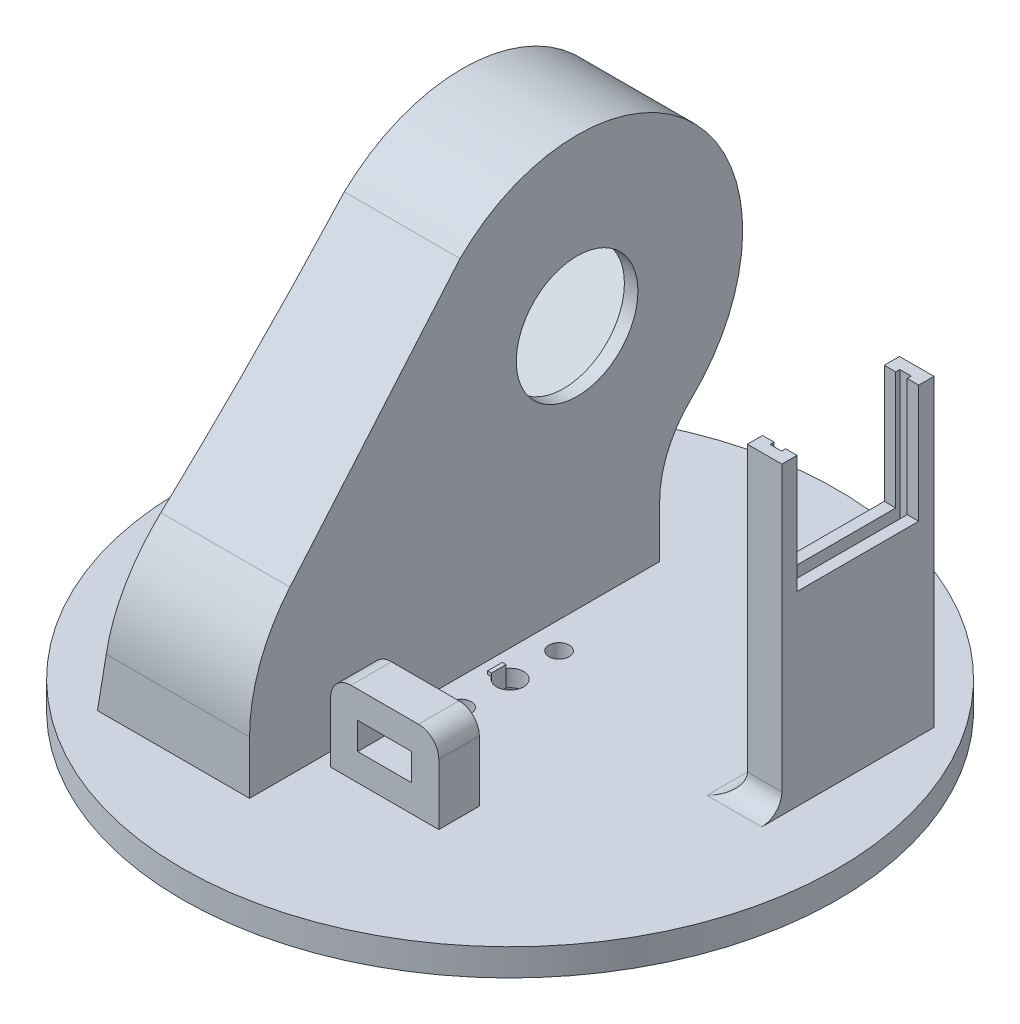
from build123d import *

# Parameters (mm, degrees)
SKETCH2_R                = 48.5
BOSS_EXTRUDE1_DEPTH      = 4
SKETCH4_R                = 1.5
CUT_EXTRUDE2_DEPTH       = 5
SKETCH5_R                = 3.75
CUT_EXTRUDE3_DEPTH       = 1.5
BOSS_EXTRUDE2_DEPTH      = 14
CUT_EXTRUDE5_REACH       = 44.5
SKETCH9_R                = 1.3
CUT_EXTRUDE6_DEPTH       = 7.5
CUT_EXTRUDE9_REACH       = 46.5
SKETCH11_R               = 9
BOSS_EXTRUDE7_DEPTH      = 9
BOSS_EXTRUDE7_DEPTH_BACK = 14
BOSS_EXTRUDE10_DEPTH     = 9
SKETCH27_W               = 16
SKETCH27_H               = 6
BOSS_EXTRUDE11_DEPTH     = 12
FILLET6_R                = 3
CUT_EXTRUDE16_REACH      = 75.05
SKETCH28_W               = 8
SKETCH28_H               = 4
CUT_EXTRUDE17_DEPTH      = 49.5
CUT_EXTRUDE17_DEPTH_BACK = 49.5
CROQUIS4_W               = 5.1
CROQUIS4_H               = 22.5
SALIENTE_EXTRUIR1_DEPTH  = 45
CROQUIS5_W               = 1.7
CROQUIS5_H               = 19.2
CORTAR_EXTRUIR1_DEPTH    = 19.5
CROQUIS6_W               = 18
CROQUIS6_H               = 17.447039648
CORTAR_EXTRUIR2_DEPTH    = 19.5
REDONDEO1_R              = 3
CROQUIS7_R               = 1.99
CORTAR_EXTRUIR3_DEPTH    = 10
CROQUIS8_W               = 0.564126112
CROQUIS8_H               = 2.164439882
SALIENTE_EXTRUIR2_DEPTH  = 3


with BuildPart() as part:
    # Sketch2 → Boss-Extrude1 (new body)
    with BuildSketch(Plane(origin=(0, 0, 0), x_dir=(1, 0, 0), z_dir=(0, 1, 0))):
        Circle(SKETCH2_R)
    extrude(amount=BOSS_EXTRUDE1_DEPTH)

    # Sketch4 → Cut-Extrude2 (cut, through all)
    with BuildSketch(Plane.XZ):
        with Locations((0, 7.25)):
            Circle(SKETCH4_R)
        with Locations((0, -7.25)):
            Circle(SKETCH4_R)
    extrude(amount=-CUT_EXTRUDE2_DEPTH, mode=Mode.SUBTRACT)

    # Sketch5 → Cut-Extrude3 (cut)
    with BuildSketch(Plane.XZ):
        Circle(SKETCH5_R)
    extrude(amount=-CUT_EXTRUDE3_DEPTH, mode=Mode.SUBTRACT)

    # Sketch7 → Boss-Extrude2 (add)
    with BuildSketch(Plane(origin=(-4, 0, 0), x_dir=(0, 0, -1), z_dir=(1, 0, 0))):
        with BuildLine():
            Line((23.129947874, 4), (23.129947874, 11.644549616))
            ThreePointArc((23.129947874, 11.644549616), (24.589048403, 18.743749901), (28.729797284, 24.692011643))
            ThreePointArc((28.729797284, 24.692011643), (29.313383054, 55.284736897), (-1.284289494, 55.479275971))
            Line((-1.284289494, 55.479275971), (-27.227315747, 29.536249718))
            ThreePointArc((-27.227315747, 29.536249718), (-32.64663453, 21.425665997), (-34.549646217, 11.858580188))
            Line((-34.549646217, 11.858580188), (-34.549646217, 4))
            Line((-34.549646217, 4), (23.129947874, 4))
        make_face()
    extrude(amount=-BOSS_EXTRUDE2_DEPTH)

    # Sketch8 → Cut-Extrude5 (cut, up to next)
    with BuildSketch(Plane(origin=(-6, 0, 0), x_dir=(0, 0, -1), z_dir=(1, 0, 0)), mode=Mode.PRIVATE) as cut_extrude5_sk1:
        Polygon((-15.249648422, 25.957567857), (13.741729607, 54.948945886), (28.590972012, 40.099703481), (-0.400406017, 11.108325452), align=None)
    cut_extrude5_tool1 = extrude(cut_extrude5_sk1.sketch, amount=-CUT_EXTRUDE5_REACH, mode=Mode.PRIVATE) & part.part
    add(cut_extrude5_tool1.solids().sort_by_distance((-6, 33.028636, -6.670662))[0], mode=Mode.SUBTRACT)

    # Sketch9 → Cut-Extrude6 (cut)
    with BuildSketch(Plane.ZY.offset(18)):
        with Locations((-20.105690637, 53.534732323)):
            Circle(SKETCH9_R)
        with Locations((-27.176758449, 46.463664511)):
            Circle(SKETCH9_R)
        with Locations((6.764367048, 12.522539014)):
            Circle(SKETCH9_R)
        with Locations((13.83543486, 19.593606826)):
            Circle(SKETCH9_R)
    extrude(amount=-CUT_EXTRUDE6_DEPTH, mode=Mode.SUBTRACT)

    # Sketch11 → Cut-Extrude9 (cut, up to next)
    with BuildSketch(Plane(origin=(-4, 0, 0), x_dir=(0, 0, -1), z_dir=(1, 0, 0)), mode=Mode.PRIVATE) as cut_extrude9_sk1:
        with Locations((13.918506302, 40.276480176)):
            Circle(SKETCH11_R)
    cut_extrude9_tool1 = extrude(cut_extrude9_sk1.sketch, amount=-CUT_EXTRUDE9_REACH, mode=Mode.PRIVATE) & part.part
    add(cut_extrude9_tool1.solids().sort_by_distance((-4, 40.27648, -13.918506))[0], mode=Mode.SUBTRACT)

    # Sketch17 → Boss-Extrude7 (add, two sides)
    with BuildSketch(Plane.ZY.offset(18)) as boss_extrude7_sk:
        with BuildLine():
            ThreePointArc((34.549646217, 11.858580188), (33.008342843, 20.500891953), (28.574482006, 28.077569775))
            ThreePointArc((28.574482006, 28.077569775), (27.915386359, 28.820289685), (27.227315747, 29.536249718))
            Line((27.227315747, 29.536249718), (1.284289494, 55.479275971))
            Line((1.284289494, 55.479275971), (26.295003593, 26.127182305))
            ThreePointArc((26.295003593, 26.127182305), (30.194232218, 19.461281607), (31.549646217, 11.858580188))
            Line((31.549646217, 11.858580188), (31.549646217, 4))
            Line((31.549646217, 4), (34.549646217, 4))
            Line((34.549646217, 4), (34.549646217, 11.858580188))
        make_face()
        with BuildLine():
            Line((28.574482006, 28.077569775), (3.405609837, 57.600596315))
            ThreePointArc((3.405609837, 57.600596315), (-31.461505391, 57.378912253), (-30.796489049, 22.517434639))
            ThreePointArc((-30.796489049, 22.517434639), (-27.345864981, 17.560549854), (-26.129947874, 11.644549616))
            Line((-26.129947874, 11.644549616), (-26.129947874, 4))
            Line((-26.129947874, 4), (-23.129947874, 4))
            Line((-23.129947874, 4), (-23.129947874, 11.644549616))
            ThreePointArc((-23.129947874, 11.644549616), (-24.589048403, 18.743749901), (-28.729797284, 24.692011643))
            ThreePointArc((-28.729797284, 24.692011643), (-29.313383054, 55.284736897), (1.284289494, 55.479275971))
            Line((1.284289494, 55.479275971), (27.227315747, 29.536249718))
            ThreePointArc((27.227315747, 29.536249718), (27.915386359, 28.820289685), (28.574482006, 28.077569775))
        make_face()
    extrude(amount=BOSS_EXTRUDE7_DEPTH)
    extrude(boss_extrude7_sk.sketch, amount=-BOSS_EXTRUDE7_DEPTH_BACK)

    # Sketch25 → Boss-Extrude10 (add)
    with BuildSketch(Plane.ZY.offset(18)):
        with BuildLine():
            ThreePointArc((-28.729797284, 24.692011643), (-24.589048403, 18.743749901), (-23.129947874, 11.644549616))
            Line((-23.129947874, 11.644549616), (-23.129947874, 4))
            Line((-23.129947874, 4), (-15.129947874, 4))
            add(Edge.make_bspline(
                [(-28.729797284, 24.692011643), (-21.954867515, 18.253200081), (-19.09405247, 12.798017691), (-15.129947874, 4)],
                knots=[0, 0, 0, 0, 1, 1, 1, 1], degree=3))
        make_face()
        with BuildLine():
            add(Edge.make_bspline(
                [(11.751619577, 43.19501844), (26.551255916, 25.8264495), (25.549646217, 4)],
                knots=[0, 0, 0, 1, 1, 1], degree=2))
            Line((25.549646217, 4), (31.549646217, 4))
            Line((31.549646217, 4), (31.549646217, 11.858580188))
            ThreePointArc((31.549646217, 11.858580188), (30.194232218, 19.461281607), (26.295003593, 26.127182305))
            Line((26.295003593, 26.127182305), (11.751619577, 43.19501844))
        make_face()
    extrude(amount=BOSS_EXTRUDE10_DEPTH)

    # Sketch27 → Boss-Extrude11 (add)
    with BuildSketch(Plane(origin=(0, 4, 0), x_dir=(1, 0, 0), z_dir=(0, 1, 0))):
        with Locations((6, -21.549646217)):
            Rectangle(SKETCH27_W, SKETCH27_H)
    extrude(amount=BOSS_EXTRUDE11_DEPTH)

    # Fillet6
    fillet6_edges = [part.edges().sort_by_distance(p)[0] for p in [
        (-2, 16, 21.549646217),
        (14, 16, 21.549646217),
    ]]
    fillet(fillet6_edges, radius=FILLET6_R)

    # Sketch28 → Cut-Extrude16 (cut, up to next)
    with BuildSketch(Plane.XY.offset(24.549646217), mode=Mode.PRIVATE) as cut_extrude16_sk1:
        with Locations((6, 10)):
            Rectangle(SKETCH28_W, SKETCH28_H)
    cut_extrude16_tool1 = extrude(cut_extrude16_sk1.sketch, amount=-CUT_EXTRUDE16_REACH, mode=Mode.PRIVATE) & part.part
    add(cut_extrude16_tool1.solids().sort_by_distance((6, 10, 24.549646))[0], mode=Mode.SUBTRACT)

    # Sketch29 → Cut-Extrude17 (cut, two sides)
    with BuildSketch(Plane.XY) as cut_extrude17_sk:
        with BuildLine():
            Line((-21, 64.776480176), (-27, 64.776480176))
            Line((-27, 64.776480176), (-27, 4))
            Line((-27, 4), (-26.5, 4))
            add(Edge.make_bspline(
                [(-21, 64.776480176), (-21.220459696, 34.140901434), (-26.5, 4)],
                knots=[0, 0, 0, 1, 1, 1], degree=2))
        make_face()
    extrude(amount=CUT_EXTRUDE17_DEPTH, mode=Mode.SUBTRACT)
    extrude(cut_extrude17_sk.sketch, amount=-CUT_EXTRUDE17_DEPTH_BACK, mode=Mode.SUBTRACT)

    # Croquis4 → Saliente-Extruir1 (add)
    with BuildSketch(Plane(origin=(0, 4, 0), x_dir=(1, 0, 0), z_dir=(0, 1, 0))):
        with Locations((35, 13.919947874)):
            Rectangle(CROQUIS4_W, CROQUIS4_H)
    extrude(amount=SALIENTE_EXTRUIR1_DEPTH)

    # Croquis5 → Cortar-Extruir1 (cut)
    with BuildSketch(Plane(origin=(0, 49, 0), x_dir=(1, 0, 0), z_dir=(0, 1, 0))):
        with Locations((35, 13.919947874)):
            Rectangle(CROQUIS5_W, CROQUIS5_H)
    extrude(amount=-CORTAR_EXTRUIR1_DEPTH, mode=Mode.SUBTRACT)

    # Croquis6 → Cortar-Extruir2 (cut)
    with BuildSketch(Plane(origin=(37.55, 0, 0), x_dir=(0, 0, -1), z_dir=(1, 0, 0))):
        with Locations((13.918506302, 40.276480176)):
            Rectangle(CROQUIS6_W, CROQUIS6_H)
    extrude(amount=-CORTAR_EXTRUIR2_DEPTH, mode=Mode.SUBTRACT)

    # Redondeo1
    redondeo1_edges = [part.edges().sort_by_distance(p)[0] for p in [
        (32.45, 4, -13.919947874),
        (35, 4, -2.669947874),
    ]]
    fillet(redondeo1_edges, radius=REDONDEO1_R)

    # Croquis7 → Cortar-Extruir3 (cut)
    with BuildSketch(Plane.XZ.offset(-1.5)):
        Circle(CROQUIS7_R)
    extrude(amount=-CORTAR_EXTRUIR3_DEPTH, mode=Mode.SUBTRACT)

    # Croquis8 → Saliente-Extruir2 (add)
    with BuildSketch(Plane.XZ.offset(-1.5)):
        with Locations((-1.952063056, 0)):
            Rectangle(CROQUIS8_W, CROQUIS8_H)
    extrude(amount=-SALIENTE_EXTRUIR2_DEPTH)


solid = part.part
